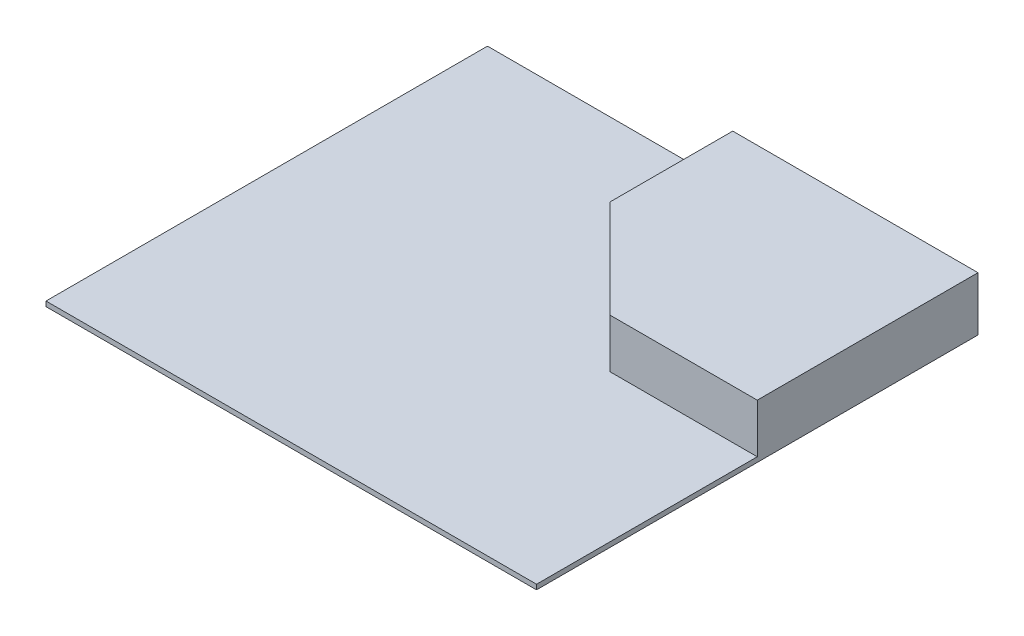
from build123d import *

# Parameters (mm, degrees)
SKETCH1_W           = 1000
SKETCH1_H           = 900
BOSS_EXTRUDE1_DEPTH = 10
BOSS_EXTRUDE2_DEPTH = 100


with BuildPart() as part:
    # Sketch1 → Boss-Extrude1 (new body)
    with BuildSketch(Plane(origin=(0, 0, 0), x_dir=(1, 0, 0), z_dir=(0, 1, 0))):
        Rectangle(SKETCH1_W, SKETCH1_H)
    extrude(amount=BOSS_EXTRUDE1_DEPTH)

    # Sketch2 → Boss-Extrude2 (add)
    with BuildSketch(Plane(origin=(0, 10, 0), x_dir=(1, 0, 0), z_dir=(0, 1, 0))):
        Polygon((0, 450), (0, 200), (200, 0), (500, 0), (500, 450), align=None)
    extrude(amount=BOSS_EXTRUDE2_DEPTH)


solid = part.part
